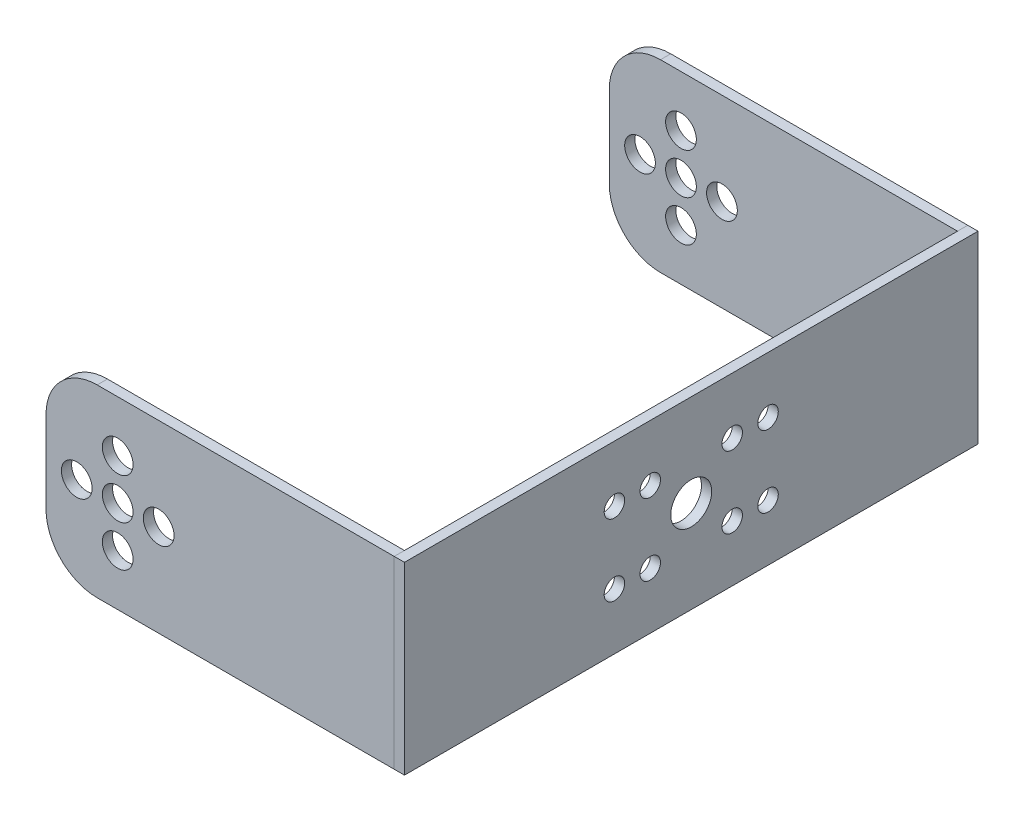
from build123d import *

# Parameters (mm, degrees)
SKETCH2_W           = 34
SKETCH2_H           = 18
BOSS_EXTRUDE1_DEPTH = 1
SKETCH4_W           = 1
SKETCH4_H           = 18
BOSS_EXTRUDE2_DEPTH = 56
SKETCH5_W           = 34
SKETCH5_H           = 18
BOSS_EXTRUDE3_DEPTH = 1
SKETCH6_R           = 1.5
CUT_EXTRUDE1_DEPTH  = 57
FILLET1_R           = 5
FILLET2_R           = 5
SKETCH7_R           = 2
SKETCH7_R_2         = 1
CUT_EXTRUDE2_DEPTH  = 53


with BuildPart() as part:
    # Sketch2 → Boss-Extrude1 (new body)
    with BuildSketch(Plane.XY):
        with Locations((17, 9)):
            Rectangle(SKETCH2_W, SKETCH2_H)
    extrude(amount=BOSS_EXTRUDE1_DEPTH)


with BuildPart() as body_2:
    # Sketch4 → Boss-Extrude2 (new body)
    with BuildSketch(Plane.XY.offset(1)):
        with Locations((34.5, 9)):
            Rectangle(SKETCH4_W, SKETCH4_H)
    extrude(amount=-BOSS_EXTRUDE2_DEPTH)

    # Sketch7 → Cut-Extrude2 (cut)
    with BuildSketch(Plane(origin=(35, 0, 0), x_dir=(0, 0, -1), z_dir=(1, 0, 0))):
        with Locations((27, 9)):
            Circle(SKETCH7_R)
        with Locations((23, 12.5)):
            Circle(SKETCH7_R_2)
        with Locations((23, 5.5)):
            Circle(SKETCH7_R_2)
        with Locations((31, 12.5)):
            Circle(SKETCH7_R_2)
        with Locations((31, 5.5)):
            Circle(SKETCH7_R_2)
        with Locations((19.5, 12.5)):
            Circle(SKETCH7_R_2)
        with Locations((19.5, 5.5)):
            Circle(SKETCH7_R_2)
        with Locations((34.5, 12.5)):
            Circle(SKETCH7_R_2)
        with Locations((34.5, 5.5)):
            Circle(SKETCH7_R_2)
    extrude(amount=-CUT_EXTRUDE2_DEPTH, mode=Mode.SUBTRACT)


with BuildPart() as body_3:
    # Sketch5 → Boss-Extrude3 (new body)
    with BuildSketch(Plane(origin=(0, 0, -55), x_dir=(-1, 0, 0), z_dir=(0, 0, -1))):
        with Locations((-17, 9)):
            Rectangle(SKETCH5_W, SKETCH5_H)
    extrude(amount=-BOSS_EXTRUDE3_DEPTH)


with BuildPart() as cut_extrude1_tool:
    # Sketch6 → Cut-Extrude1 (new body)
    with BuildSketch(Plane(origin=(0, 0, -55), x_dir=(-1, 0, 0), z_dir=(0, 0, -1))):
        with Locations((-3, 9)):
            Circle(SKETCH6_R)
        with Locations((-7, 9)):
            Circle(SKETCH6_R)
        with Locations((-7, 13)):
            Circle(SKETCH6_R)
        with Locations((-7, 5)):
            Circle(SKETCH6_R)
        with Locations((-11, 9)):
            Circle(SKETCH6_R)
    extrude(amount=-CUT_EXTRUDE1_DEPTH)


with BuildPart() as part_1:
    add(part.part)

    # Cut-Extrude1: cut by cut_extrude1_tool
    add(cut_extrude1_tool.part, mode=Mode.SUBTRACT)

    # Fillet2
    fillet2_edges = [part_1.edges().sort_by_distance(p)[0] for p in [
        (0, 18, 0.5),
        (0, 0, 0.5),
    ]]
    fillet(fillet2_edges, radius=FILLET2_R)


with BuildPart() as body_3_1:
    add(body_3.part)

    # Cut-Extrude1: cut by cut_extrude1_tool
    add(cut_extrude1_tool.part, mode=Mode.SUBTRACT)

    # Fillet1
    fillet1_edges = [body_3_1.edges().sort_by_distance(p)[0] for p in [
        (0, 18, -54.5),
        (0, 0, -54.5),
    ]]
    fillet(fillet1_edges, radius=FILLET1_R)


solid = Compound([body_2.part, part_1.part, body_3_1.part])
